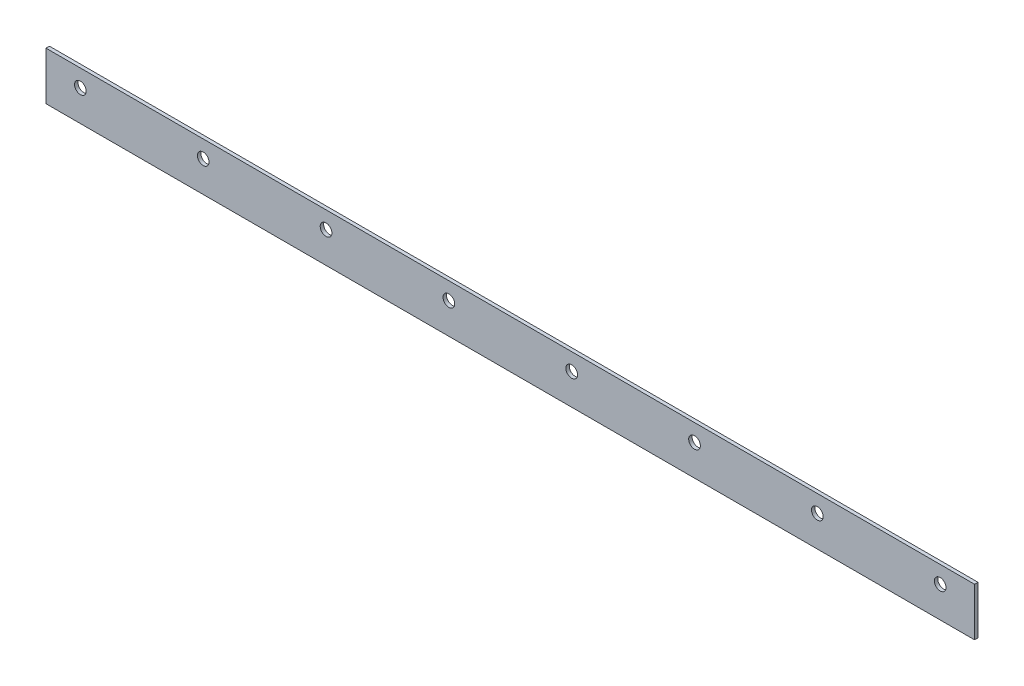
from build123d import *

# Parameters (mm, degrees)
SKETCH1_W            = 270
SKETCH1_H            = 14
BOSS_EXTRUDE1_DEPTH  = 1
M3_CLEARANCE_HOLE1_D = 3.4
LPATTERN1_COUNT      = 8
LPATTERN1_PITCH      = 35.714285714


with BuildPart() as part:
    # Sketch1 → Boss-Extrude1 (new body)
    with BuildSketch(Plane.XY):
        Rectangle(SKETCH1_W, SKETCH1_H)
    extrude(amount=BOSS_EXTRUDE1_DEPTH)

    # M3 Clearance Hole1 (through all)
    with Locations(Plane.XY.offset(1)):
        with Locations((125, 2)):
            m3_clearance_hole1 = Hole(M3_CLEARANCE_HOLE1_D / 2)

    # LPattern1: M3 Clearance Hole1 ×8
    with Locations(*[(-i * LPATTERN1_PITCH, 0, 0) for i in range(1, LPATTERN1_COUNT)]):
        add(m3_clearance_hole1, mode=Mode.SUBTRACT)


solid = part.part
